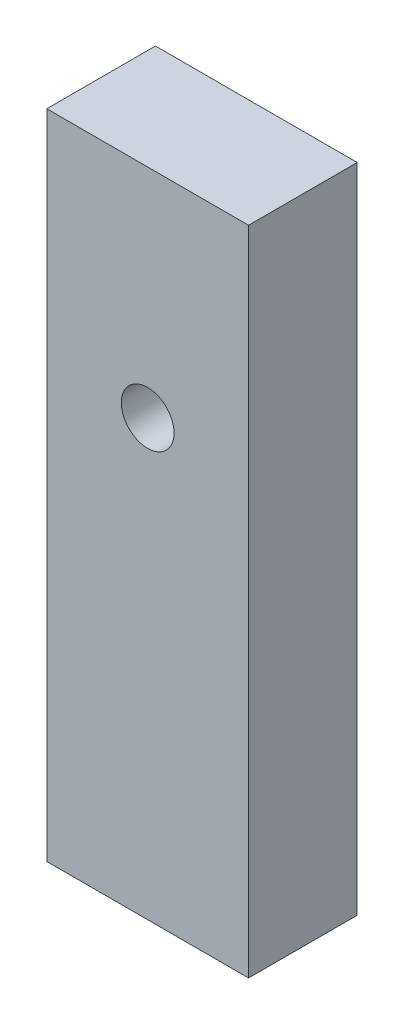
from build123d import *

# Parameters (mm, degrees)
SKETCH1_W           = 13
SKETCH1_H           = 42
BOSS_EXTRUDE1_DEPTH = 7
SKETCH2_W           = 11
SKETCH2_H           = 3.6
CUT_EXTRUDE1_DEPTH  = 4
SKETCH3_R           = 1.7
CUT_EXTRUDE2_DEPTH  = 10


with BuildPart() as part:
    # Sketch1 → Boss-Extrude1 (new body)
    with BuildSketch(Plane.XY):
        with Locations((-19.139592704, 35.078039657)):
            Rectangle(SKETCH1_W, SKETCH1_H)
    extrude(amount=BOSS_EXTRUDE1_DEPTH)

    # Sketch2 → Cut-Extrude1 (cut)
    with BuildSketch(Plane(origin=(0, 0, 0), x_dir=(-1, 0, 0), z_dir=(0, 0, -1))):
        with Locations((19.139592704, 35.078039657)):
            Rectangle(SKETCH2_W, SKETCH2_H)
    extrude(amount=-CUT_EXTRUDE1_DEPTH, mode=Mode.SUBTRACT)

    # Sketch3 → Cut-Extrude2 (cut)
    with BuildSketch(Plane.XY):
        with Locations((-19.139592704, 42.078039657)):
            Circle(SKETCH3_R)
    extrude(amount=CUT_EXTRUDE2_DEPTH, mode=Mode.SUBTRACT)


solid = part.part
